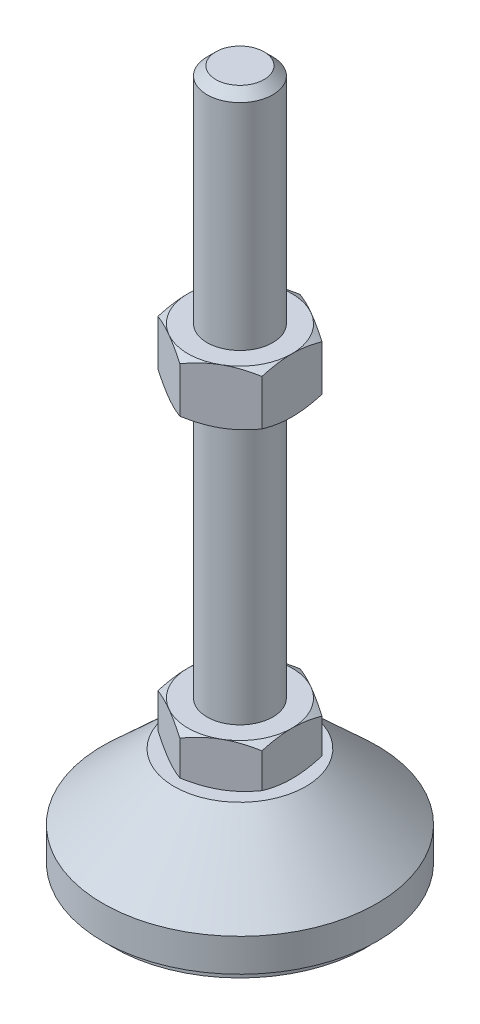
from build123d import *

# Parameters (mm, degrees)
EXTRUDE_1_DEPTH = 8
EXTRUDE_2_DEPTH = 10


with BuildPart() as part:
    # Эскиз1 → Повернуть1 (revolve)
    with BuildSketch(Plane.XY, mode=Mode.PRIVATE) as revolve_1_sk:
        Polygon((0, 0), (-23, 0), (-23, 2), (-25, 2), (-25, 8), (-12, 20), (-6, 20), (-6, 28), (-6, 126.4), (-4.4, 128), (0, 128), align=None)
    revolve(revolve_1_sk.sketch.rotate(Axis((0, 0, 0), (0, 1, 0)), 180), axis=Axis((0, 0, 0), (0, 1, 0)))  # turned: the seam where the file's is

    # Эскиз2 → Бобышка-Вытянуть1 (add)
    with BuildSketch(Plane(origin=(0, 20, 0), x_dir=(1, 0, 0), z_dir=(0, 1, 0))):
        Polygon((0, 10.969655115), (-9.5, 5.484827557), (-9.5, -5.484827557), (0, -10.969655115), (9.5, -5.484827557), (9.5, 5.484827557), align=None)
    extrude(amount=EXTRUDE_1_DEPTH)

    # Эскиз3 → Бобышка-Вытянуть2 (add)
    with BuildSketch(Plane(origin=(0, 77.2, 0), x_dir=(1, 0, 0), z_dir=(0, 1, 0))):
        Polygon((9.5, 5.484827557), (0, 10.969655115), (-9.5, 5.484827557), (-9.5, -5.484827557), (0, -10.969655115), (9.5, -5.484827557), align=None)
    extrude(amount=EXTRUDE_2_DEPTH)

    # Эскиз4 → Вырез-Повернуть2 (revolve, cut)
    with BuildSketch(Plane.XY, mode=Mode.PRIVATE) as cut_revolve_2_sk:
        Polygon((-18.160254038, 87.2), (-9.5, 87.2), (-18.160254038, 82.2), align=None)
        Polygon((-18.160254038, 77.2), (-18.160254038, 82.2), (-9.5, 77.2), align=None)
        Polygon((-16.42820323, 28), (-16.42820323, 24), (-9.5, 28), align=None)
        Polygon((-16.42820323, 24), (-16.42820323, 20), (-9.5, 20), align=None)
    revolve(cut_revolve_2_sk.sketch.rotate(Axis((0, 128, 0), (0, -1, 0)), 180), axis=Axis((0, 128, 0), (0, -1, 0)), mode=Mode.SUBTRACT)  # turned: the seam where the file's is


solid = part.part
